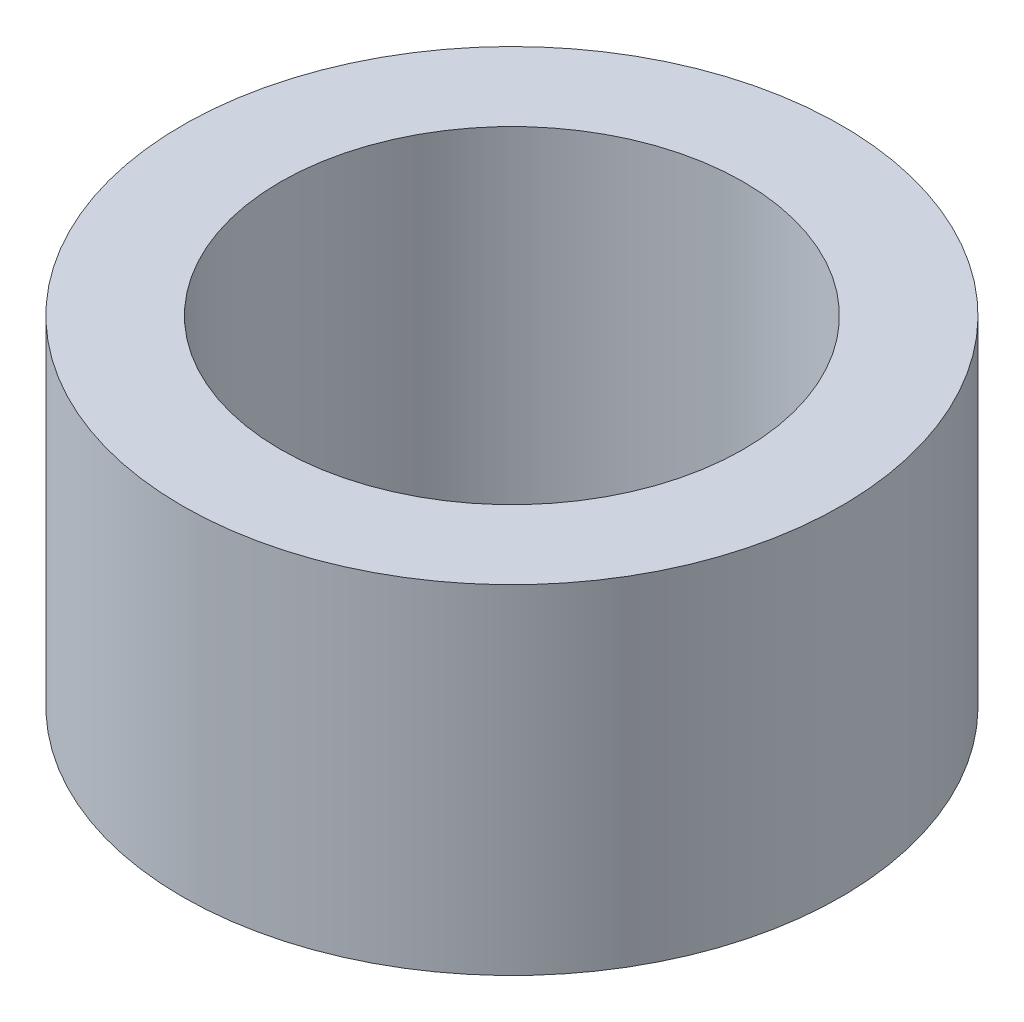
from build123d import *

# Parameters (mm, degrees)
SKETCH1_R           = 4.699
SKETCH1_R_2         = 3.302
BOSS_EXTRUDE1_DEPTH = 4.826


with BuildPart() as part:
    # Sketch1 → Boss-Extrude1 (new body)
    with BuildSketch(Plane(origin=(0, 0, 0), x_dir=(1, 0, 0), z_dir=(0, 1, 0))):
        Circle(SKETCH1_R)
        Circle(SKETCH1_R_2, mode=Mode.SUBTRACT)
    extrude(amount=BOSS_EXTRUDE1_DEPTH)


solid = part.part
